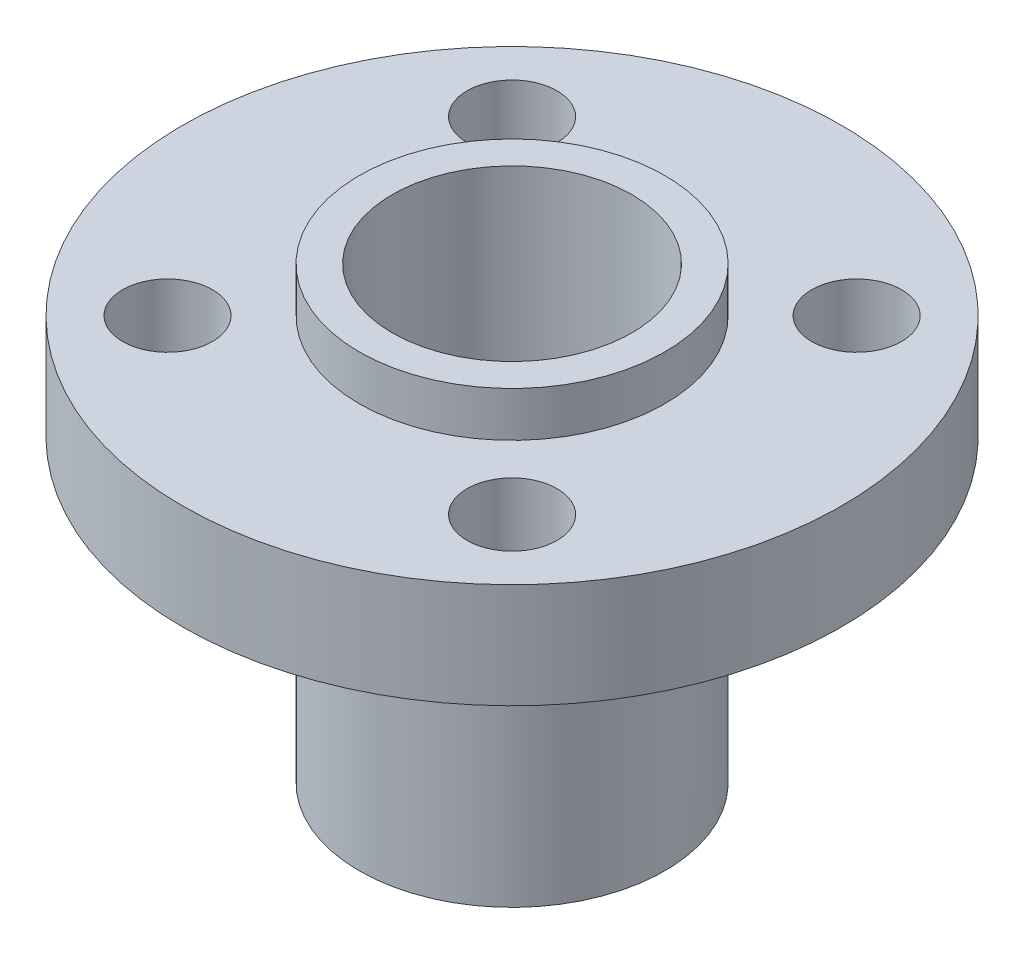
from build123d import *

# Parameters (mm, degrees)
SKETCH1_R           = 11
SKETCH1_R_2         = 4
BOSS_EXTRUDE1_DEPTH = 3.5
SKETCH2_R           = 5.1
SKETCH2_R_2         = 4
BOSS_EXTRUDE2_DEPTH = 1.5
SKETCH3_R           = 5.1
SKETCH3_R_2         = 4
BOSS_EXTRUDE3_DEPTH = 10
CUT_EXTRUDE1_REACH  = 15.5
SKETCH4_R           = 1.5


with BuildPart() as part:
    # Sketch1 → Boss-Extrude1 (new body)
    with BuildSketch(Plane(origin=(0, 0, 0), x_dir=(1, 0, 0), z_dir=(0, 1, 0))):
        Circle(SKETCH1_R)
        Circle(SKETCH1_R_2, mode=Mode.SUBTRACT)
    extrude(amount=BOSS_EXTRUDE1_DEPTH)

    # Sketch2 → Boss-Extrude2 (add)
    with BuildSketch(Plane(origin=(0, 3.5, 0), x_dir=(1, 0, 0), z_dir=(0, 1, 0))):
        Circle(SKETCH2_R)
        Circle(SKETCH2_R_2, mode=Mode.SUBTRACT)
    extrude(amount=BOSS_EXTRUDE2_DEPTH)

    # Sketch3 → Boss-Extrude3 (add)
    with BuildSketch(Plane.XZ):
        Circle(SKETCH3_R)
        Circle(SKETCH3_R_2, mode=Mode.SUBTRACT)
    extrude(amount=BOSS_EXTRUDE3_DEPTH)

    # Sketch4 → Cut-Extrude1 (cut, up to next)
    with BuildSketch(Plane(origin=(0, 3.5, 0), x_dir=(1, 0, 0), z_dir=(0, 1, 0)), mode=Mode.PRIVATE) as cut_extrude1_sk1:
        with Locations((-5.75, 5.75)):
            Circle(SKETCH4_R)
    cut_extrude1_tool1 = extrude(cut_extrude1_sk1.sketch, amount=-CUT_EXTRUDE1_REACH, mode=Mode.PRIVATE) & part.part
    add(cut_extrude1_tool1.solids().sort_by_distance((-5.75, 3.5, -5.75))[0], mode=Mode.SUBTRACT)
    # Sketch4 → Cut-Extrude1 (cut, up to next)
    with BuildSketch(Plane(origin=(0, 3.5, 0), x_dir=(1, 0, 0), z_dir=(0, 1, 0)), mode=Mode.PRIVATE) as cut_extrude1_sk2:
        with Locations((5.75, 5.75)):
            Circle(SKETCH4_R)
    cut_extrude1_tool2 = extrude(cut_extrude1_sk2.sketch, amount=-CUT_EXTRUDE1_REACH, mode=Mode.PRIVATE) & part.part
    add(cut_extrude1_tool2.solids().sort_by_distance((5.75, 3.5, -5.75))[0], mode=Mode.SUBTRACT)
    # Sketch4 → Cut-Extrude1 (cut, up to next)
    with BuildSketch(Plane(origin=(0, 3.5, 0), x_dir=(1, 0, 0), z_dir=(0, 1, 0)), mode=Mode.PRIVATE) as cut_extrude1_sk3:
        with Locations((5.75, -5.75)):
            Circle(SKETCH4_R)
    cut_extrude1_tool3 = extrude(cut_extrude1_sk3.sketch, amount=-CUT_EXTRUDE1_REACH, mode=Mode.PRIVATE) & part.part
    add(cut_extrude1_tool3.solids().sort_by_distance((5.75, 3.5, 5.75))[0], mode=Mode.SUBTRACT)
    # Sketch4 → Cut-Extrude1 (cut, up to next)
    with BuildSketch(Plane(origin=(0, 3.5, 0), x_dir=(1, 0, 0), z_dir=(0, 1, 0)), mode=Mode.PRIVATE) as cut_extrude1_sk4:
        with Locations((-5.75, -5.75)):
            Circle(SKETCH4_R)
    cut_extrude1_tool4 = extrude(cut_extrude1_sk4.sketch, amount=-CUT_EXTRUDE1_REACH, mode=Mode.PRIVATE) & part.part
    add(cut_extrude1_tool4.solids().sort_by_distance((-5.75, 3.5, 5.75))[0], mode=Mode.SUBTRACT)


solid = part.part
